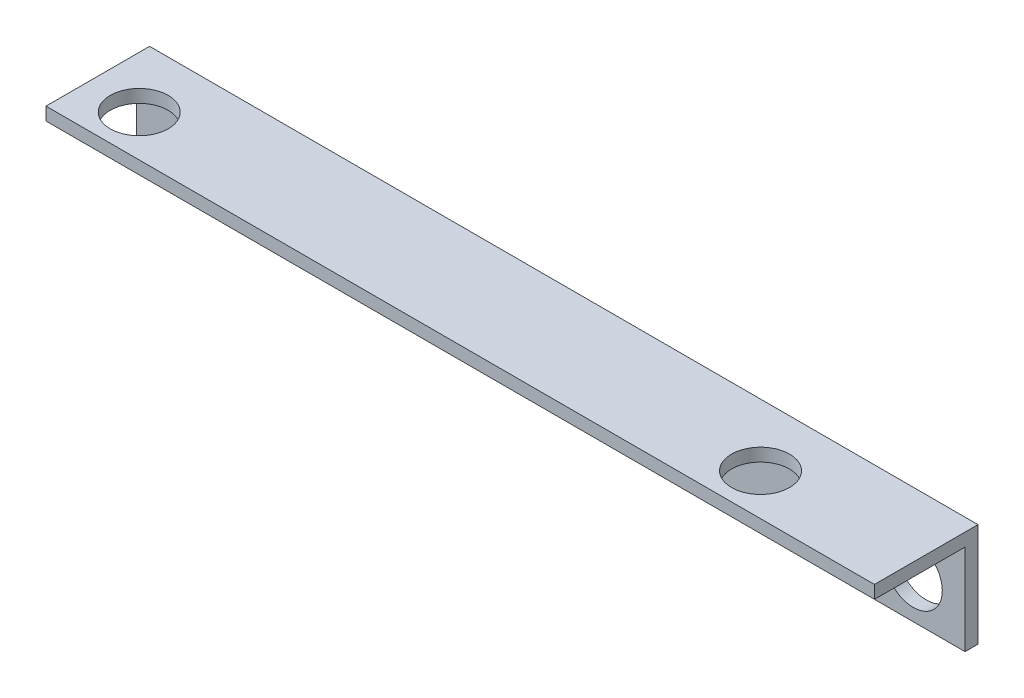
from build123d import *

# Parameters (mm, degrees)
BOSS_EXTRUDE1_DEPTH      = 57.15
BOSS_EXTRUDE1_DEPTH_BACK = 44.45
SKETCH3_R                = 3.556
CUT_EXTRUDE1_DEPTH       = 13.7
SKETCH4_R                = 3.556
CUT_EXTRUDE2_DEPTH       = 13.7


with BuildPart() as part:
    # Sketch1 → Boss-Extrude1 (new body, two sides)
    with BuildSketch(Plane(origin=(0, 0, 0), x_dir=(0, 0, -1), z_dir=(1, 0, 0))) as boss_extrude1_sk:
        Polygon((0, 0), (0, 12.7), (-12.7, 12.7), (-12.7, 11.1125), (-1.5875, 11.1125), (-1.5875, 0), align=None)
    extrude(amount=BOSS_EXTRUDE1_DEPTH)
    extrude(boss_extrude1_sk.sketch, amount=-BOSS_EXTRUDE1_DEPTH_BACK)

    # Sketch3 → Cut-Extrude1 (cut, through all)
    with BuildSketch(Plane(origin=(0, 0, 0), x_dir=(-1, 0, 0), z_dir=(0, 0, -1))):
        with Locations((25.4, 5.08)):
            Circle(SKETCH3_R)
        with Locations((-50.8, 5.08)):
            Circle(SKETCH3_R)
    extrude(amount=-CUT_EXTRUDE1_DEPTH, mode=Mode.SUBTRACT)

    # Sketch4 → Cut-Extrude2 (cut, through all)
    with BuildSketch(Plane(origin=(0, 12.7, 0), x_dir=(1, 0, 0), z_dir=(0, 1, 0))):
        with Locations((-38.1, -7.62)):
            Circle(SKETCH4_R)
        with Locations((38.1, -7.62)):
            Circle(SKETCH4_R)
    extrude(amount=-CUT_EXTRUDE2_DEPTH, mode=Mode.SUBTRACT)


solid = part.part
